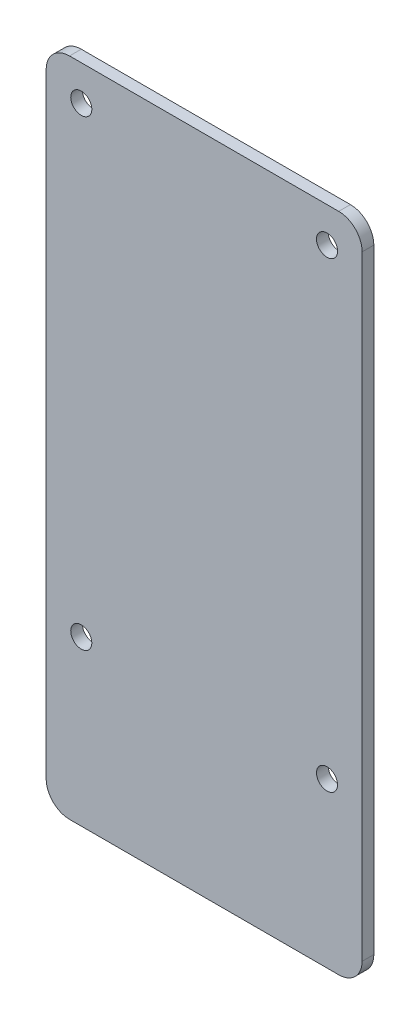
from build123d import *

# Parameters (mm, degrees)
BOSS_EXTRUDE1_DEPTH     = 2
CUT_EXTRUDE1_DEPTH      = 170.909487973
CUT_EXTRUDE1_DEPTH_BACK = 170.909487973
SKETCH2_R               = 1.8


with BuildPart() as part:
    # Sketch1 → Boss-Extrude1 (new body)
    with BuildSketch(Plane.XY):
        with BuildLine():
            Line((-140.00000048, 89.00000126), (-93.99999888, 89.00000126))
            ThreePointArc((-93.99999888, 89.00000126), (-91.171571755, 87.828428385), (-89.99999888, 85.00000126))
            Line((-89.99999888, 85.00000126), (-89.99999888, -19.99999918))
            ThreePointArc((-89.99999888, -19.99999918), (-91.171571755, -22.828426305), (-93.99999888, -23.99999918))
            Line((-93.99999888, -23.99999918), (-140.00000048, -23.99999918))
            ThreePointArc((-140.00000048, -23.99999918), (-142.828427605, -22.828426305), (-144.00000048, -19.99999918))
            Line((-144.00000048, -19.99999918), (-144.00000048, 85.00000126))
            ThreePointArc((-144.00000048, 85.00000126), (-142.828427605, 87.828428385), (-140.00000048, 89.00000126))
        make_face()
    extrude(amount=BOSS_EXTRUDE1_DEPTH)

    # Sketch2 → Cut-Extrude1 (cut, two sides: drawn at the far end of the back side and taken through both)
    with BuildSketch(Plane(origin=(0, 0, -12.56824426), x_dir=(-1, 0, 0), z_dir=(0, 0, -1)).offset(-CUT_EXTRUDE1_DEPTH_BACK)):
        with Locations((95.9999985, 82.99999962)):
            Circle(SKETCH2_R)
        with Locations((137.9999985, 82.99999962)):
            Circle(SKETCH2_R)
        with Locations((137.9999985, 3.99999962)):
            Circle(SKETCH2_R)
        with Locations((95.9999985, 3.99999962)):
            Circle(SKETCH2_R)
    extrude(amount=CUT_EXTRUDE1_DEPTH + CUT_EXTRUDE1_DEPTH_BACK, mode=Mode.SUBTRACT)


solid = part.part
